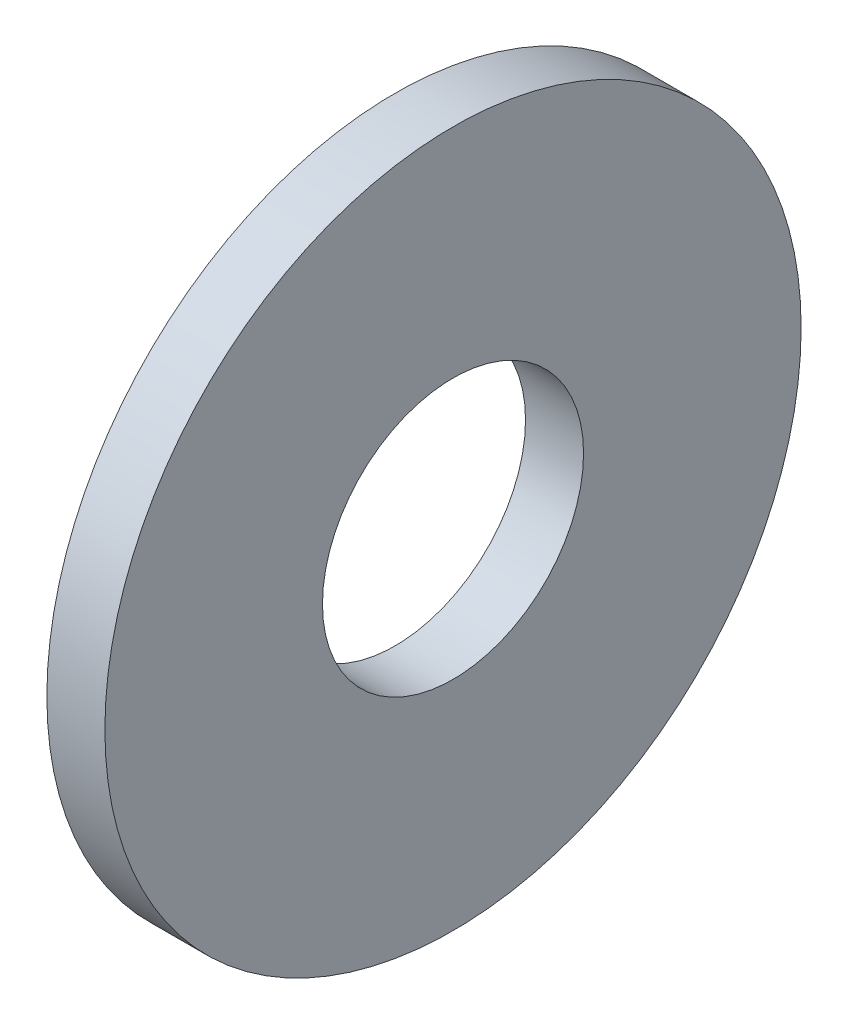
from build123d import *

# Parameters (mm, degrees)
SKETCH1_R           = 38.1
SKETCH1_R_2         = 14.2875
BOSS_EXTRUDE1_DEPTH = 3.175


with BuildPart() as part:
    # Sketch1 → Boss-Extrude1 (new body, symmetric)
    with BuildSketch(Plane(origin=(0, 0, 0), x_dir=(0, 0, -1), z_dir=(1, 0, 0))):
        Circle(SKETCH1_R)
        Circle(SKETCH1_R_2, mode=Mode.SUBTRACT)
    extrude(amount=BOSS_EXTRUDE1_DEPTH, both=True)


solid = part.part
